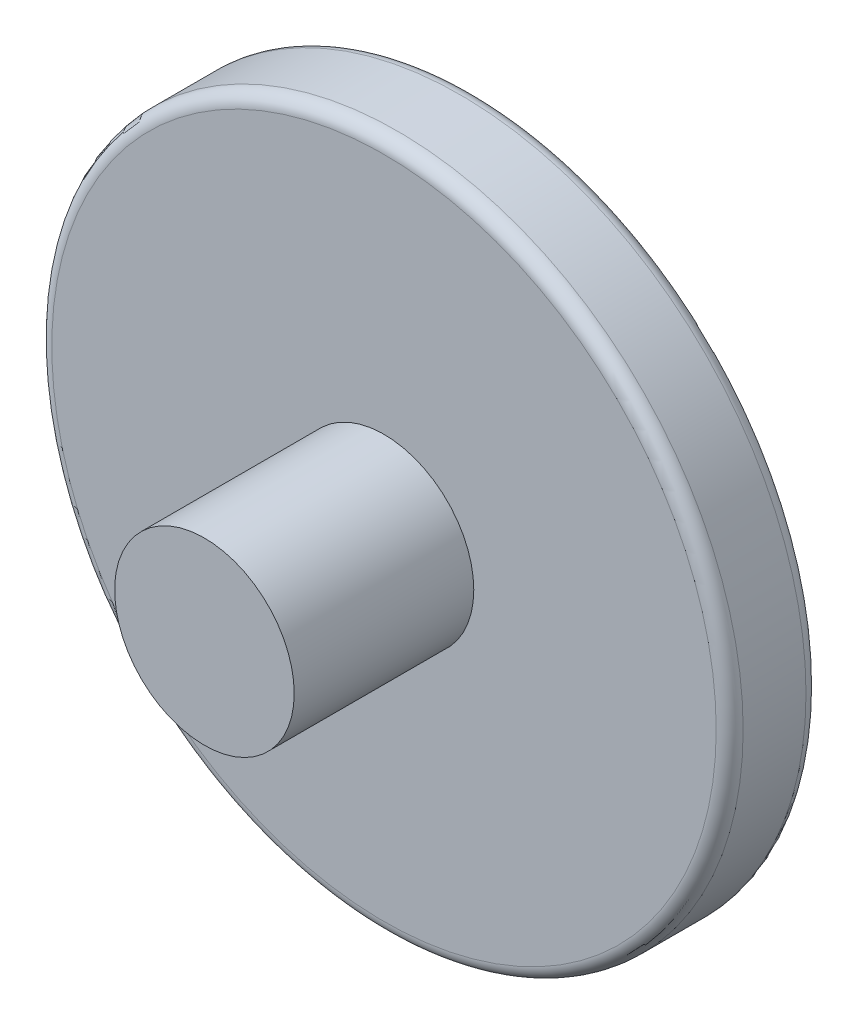
from build123d import *

# Parameters (mm, degrees)
SKETCH1_R      = 7.7
EXTRUDE1_DEPTH = 2
FILLET1_R      = 0.3
EXTRUDE2_DEPTH = 1.5
FILLET2_R      = 0.3
SKETCH3_R      = 2
EXTRUDE4_DEPTH = 4


with BuildPart() as part:
    # Sketch1 → Extrude1 (new body)
    with BuildSketch(Plane.XY):
        Circle(SKETCH1_R)
    extrude(amount=EXTRUDE1_DEPTH)

    # Fillet1
    fillet1_edges = [part.edges().sort_by_distance(p)[0] for p in [
        (-7.7, 0, 0),
        (-7.7, 0, 2),
    ]]
    fillet(fillet1_edges, radius=FILLET1_R)

    # Sketch2 → Extrude2 (cut)
    with BuildSketch(Plane(origin=(0, 0, 0), x_dir=(-1, 0, 0), z_dir=(0, 0, -1))):
        Polygon((3.049554036, 0), (1.524777018, 2.640991265), (-1.524777018, 2.640991265), (-3.049554036, 0), (-1.524777018, -2.640991265), (1.524777018, -2.640991265), align=None)
    extrude(amount=-EXTRUDE2_DEPTH, mode=Mode.SUBTRACT)

    # Fillet2
    fillet2_edges = [part.edges().sort_by_distance(p)[0] for p in [
        (-2.287165527, -1.320495633, 1.5),
        (-3.049554036, 0, 0.75),
        (0, -2.640991265, 1.5),
        (-1.524777018, -2.640991265, 0.75),
        (2.287165527, -1.320495633, 1.5),
        (1.524777018, -2.640991265, 0.75),
        (2.287165527, 1.320495633, 1.5),
        (3.049554036, 0, 0.75),
        (0, 2.640991265, 1.5),
        (1.524777018, 2.640991265, 0.75),
        (-2.287165527, 1.320495633, 1.5),
        (-1.524777018, 2.640991265, 0.75),
        (-2.287165527, -1.320495633, 0),
        (-2.287165527, 1.320495633, 0),
        (0, 2.640991265, 0),
        (2.287165527, 1.320495633, 0),
        (2.287165527, -1.320495633, 0),
        (0, -2.640991265, 0),
    ]]
    fillet(fillet2_edges, radius=FILLET2_R)

    # Sketch3 → Extrude4 (add)
    with BuildSketch(Plane.XY.offset(2)):
        Circle(SKETCH3_R)
    extrude(amount=EXTRUDE4_DEPTH)


solid = part.part
